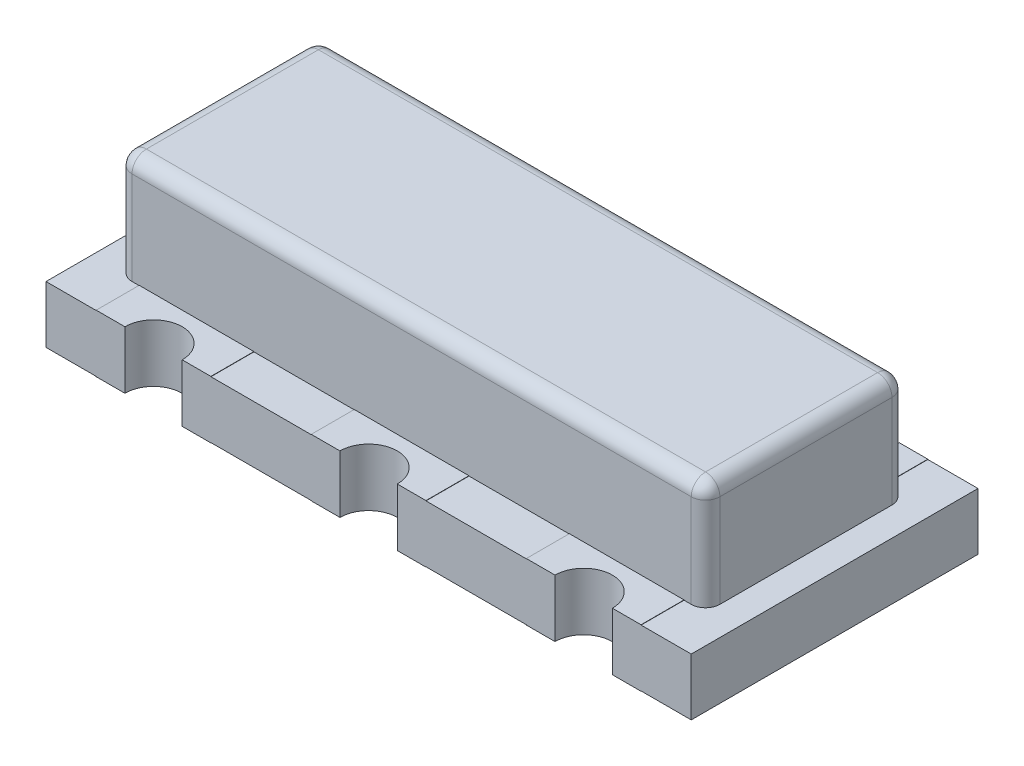
from build123d import *

# Parameters (mm, degrees)
EXTRUDE1_START = 0.002
EXTRUDE1_DEPTH = 0.398
EXTRUDE2_REACH = 2.4
EXTRUDE3_DEPTH = 0.002
SKETCH4_W      = 4.1
SKETCH4_H      = 1.4
EXTRUDE4_DEPTH = 0.75
FILLET1_R      = 0.1


with BuildPart() as part:
    # Sketch1 → Extrude1 (new body)
    with BuildSketch(Plane(origin=(0, 0, 0), x_dir=(1, 0, 0), z_dir=(0, 1, 0)).offset(EXTRUDE1_START)):
        with BuildLine():
            Line((1.7, -1), (2.25, -1))
            Line((2.25, -1), (2.25, 1))
            Line((2.25, 1), (1.7, 1))
            ThreePointArc((1.7, 1), (1.5, 0.8), (1.3, 1))
            Line((1.3, 1), (0.2, 1))
            ThreePointArc((0.2, 1), (0, 0.8), (-0.2, 1))
            Line((-0.2, 1), (-1.3, 1))
            ThreePointArc((-1.3, 1), (-1.5, 0.8), (-1.7, 1))
            Line((-1.7, 1), (-2.25, 1))
            Line((-2.25, 1), (-2.25, -1))
            Line((-2.25, -1), (-1.7, -1))
            ThreePointArc((-1.7, -1), (-1.5, -0.8), (-1.3, -1))
            Line((-1.3, -1), (-0.2, -1))
            ThreePointArc((-0.2, -1), (0, -0.8), (0.2, -1))
            Line((0.2, -1), (1.3, -1))
            ThreePointArc((1.3, -1), (1.5, -0.8), (1.7, -1))
        make_face()
    extrude(amount=EXTRUDE1_DEPTH)

    # Sketch2 → Extrude2 (add, up to next)
    with BuildSketch(Plane(origin=(0, 0, 0), x_dir=(1, 0, 0), z_dir=(0, 1, 0)), mode=Mode.PRIVATE) as extrude2_sk1:
        with BuildLine():
            Line((-1.9, -1), (-1.7, -1))
            ThreePointArc((-1.7, -1), (-1.5, -0.8), (-1.3, -1))
            Line((-1.3, -1), (-1.1, -1))
            Line((-1.1, -1), (-1.1, -0.7))
            Line((-1.1, -0.7), (-1.3, -0.7))
            Line((-1.3, -0.7), (-1.3, 0.7))
            Line((-1.3, 0.7), (-1.1, 0.7))
            Line((-1.1, 0.7), (-1.1, 1))
            Line((-1.1, 1), (-1.3, 1))
            ThreePointArc((-1.3, 1), (-1.5, 0.8), (-1.7, 1))
            Line((-1.7, 1), (-1.9, 1))
            Line((-1.9, 1), (-1.9, 0.7))
            Line((-1.9, 0.7), (-1.7, 0.7))
            Line((-1.7, 0.7), (-1.7, -0.7))
            Line((-1.7, -0.7), (-1.9, -0.7))
            Line((-1.9, -0.7), (-1.9, -1))
        make_face()
    extrude2_tool1 = extrude(extrude2_sk1.sketch, amount=EXTRUDE2_REACH, mode=Mode.PRIVATE) - part.part
    add(extrude2_tool1.solids().sort_by_distance((-1.5, 0, 0))[0])
    # Sketch2 → Extrude2 (add, up to next)
    with BuildSketch(Plane(origin=(0, 0, 0), x_dir=(1, 0, 0), z_dir=(0, 1, 0)), mode=Mode.PRIVATE) as extrude2_sk2:
        with BuildLine():
            Line((-0.4, -1), (-0.2, -1))
            ThreePointArc((-0.2, -1), (0, -0.8), (0.2, -1))
            Line((0.2, -1), (0.4, -1))
            Line((0.4, -1), (0.4, -0.7))
            Line((0.4, -0.7), (0.2, -0.7))
            Line((0.2, -0.7), (0.2, 0.7))
            Line((0.2, 0.7), (0.4, 0.7))
            Line((0.4, 0.7), (0.4, 1))
            Line((0.4, 1), (0.2, 1))
            ThreePointArc((0.2, 1), (0, 0.8), (-0.2, 1))
            Line((-0.2, 1), (-0.4, 1))
            Line((-0.4, 1), (-0.4, 0.7))
            Line((-0.4, 0.7), (-0.2, 0.7))
            Line((-0.2, 0.7), (-0.2, -0.7))
            Line((-0.2, -0.7), (-0.4, -0.7))
            Line((-0.4, -0.7), (-0.4, -1))
        make_face()
    extrude2_tool2 = extrude(extrude2_sk2.sketch, amount=EXTRUDE2_REACH, mode=Mode.PRIVATE) - part.part
    add(extrude2_tool2.solids().sort_by_distance((0, 0, 0))[0])
    # Sketch2 → Extrude2 (add, up to next)
    with BuildSketch(Plane(origin=(0, 0, 0), x_dir=(1, 0, 0), z_dir=(0, 1, 0)), mode=Mode.PRIVATE) as extrude2_sk3:
        with BuildLine():
            Line((1.1, -1), (1.3, -1))
            ThreePointArc((1.3, -1), (1.5, -0.8), (1.7, -1))
            Line((1.7, -1), (1.9, -1))
            Line((1.9, -1), (1.9, -0.7))
            Line((1.9, -0.7), (1.7, -0.7))
            Line((1.7, -0.7), (1.7, 0.7))
            Line((1.7, 0.7), (1.9, 0.7))
            Line((1.9, 0.7), (1.9, 1))
            Line((1.9, 1), (1.7, 1))
            ThreePointArc((1.7, 1), (1.5, 0.8), (1.3, 1))
            Line((1.3, 1), (1.1, 1))
            Line((1.1, 1), (1.1, 0.7))
            Line((1.1, 0.7), (1.3, 0.7))
            Line((1.3, 0.7), (1.3, -0.7))
            Line((1.3, -0.7), (1.1, -0.7))
            Line((1.1, -0.7), (1.1, -1))
        make_face()
    extrude2_tool3 = extrude(extrude2_sk3.sketch, amount=EXTRUDE2_REACH, mode=Mode.PRIVATE) - part.part
    add(extrude2_tool3.solids().sort_by_distance((1.5, 0, 0))[0])

    # Sketch3 → Extrude3 (add)
    with BuildSketch(Plane(origin=(0, 0.4, 0), x_dir=(1, 0, 0), z_dir=(0, 1, 0))):
        with BuildLine():
            Line((-1.9, -1), (-1.7, -1))
            ThreePointArc((-1.7, -1), (-1.5, -0.8), (-1.3, -1))
            Line((-1.3, -1), (-1.1, -1))
            Line((-1.1, -1), (-1.1, -0.7))
            Line((-1.1, -0.7), (-1.9, -0.7))
            Line((-1.9, -0.7), (-1.9, -1))
        make_face()
        with BuildLine():
            Line((-0.4, -1), (-0.2, -1))
            ThreePointArc((-0.2, -1), (0, -0.8), (0.2, -1))
            Line((0.2, -1), (0.4, -1))
            Line((0.4, -1), (0.4, -0.7))
            Line((0.4, -0.7), (-0.4, -0.7))
            Line((-0.4, -0.7), (-0.4, -1))
        make_face()
        with BuildLine():
            Line((1.1, -1), (1.3, -1))
            ThreePointArc((1.3, -1), (1.5, -0.8), (1.7, -1))
            Line((1.7, -1), (1.9, -1))
            Line((1.9, -1), (1.9, -0.7))
            Line((1.9, -0.7), (1.1, -0.7))
            Line((1.1, -0.7), (1.1, -1))
        make_face()
        with BuildLine():
            Line((-1.3, 1), (-1.1, 1))
            Line((-1.1, 1), (-1.1, 0.7))
            Line((-1.1, 0.7), (-1.9, 0.7))
            Line((-1.9, 0.7), (-1.9, 1))
            Line((-1.9, 1), (-1.7, 1))
            ThreePointArc((-1.7, 1), (-1.5, 0.8), (-1.3, 1))
        make_face()
        with BuildLine():
            Line((0.2, 1), (0.4, 1))
            Line((0.4, 1), (0.4, 0.7))
            Line((0.4, 0.7), (-0.4, 0.7))
            Line((-0.4, 0.7), (-0.4, 1))
            Line((-0.4, 1), (-0.2, 1))
            ThreePointArc((-0.2, 1), (0, 0.8), (0.2, 1))
        make_face()
        with BuildLine():
            Line((1.7, 1), (1.9, 1))
            Line((1.9, 1), (1.9, 0.7))
            Line((1.9, 0.7), (1.1, 0.7))
            Line((1.1, 0.7), (1.1, 1))
            Line((1.1, 1), (1.3, 1))
            ThreePointArc((1.3, 1), (1.5, 0.8), (1.7, 1))
        make_face()
    extrude(amount=EXTRUDE3_DEPTH)

    # Sketch4 → Extrude4 (add)
    with BuildSketch(Plane(origin=(0, 0.4, 0), x_dir=(1, 0, 0), z_dir=(0, 1, 0))):
        Rectangle(SKETCH4_W, SKETCH4_H)
    extrude(amount=EXTRUDE4_DEPTH)

    # Fillet1
    fillet1_edges = [part.edges().sort_by_distance(p)[0] for p in [
        (2.05, 0.775, -0.7),
        (-2.05, 0.775, 0.7),
        (-2.05, 0.775, -0.7),
        (2.05, 0.775, 0.7),
        (-2.05, 1.15, 0),
        (0, 1.15, 0.7),
        (2.05, 1.15, 0),
        (0, 1.15, -0.7),
    ]]
    fillet(fillet1_edges, radius=FILLET1_R)


solid = part.part
